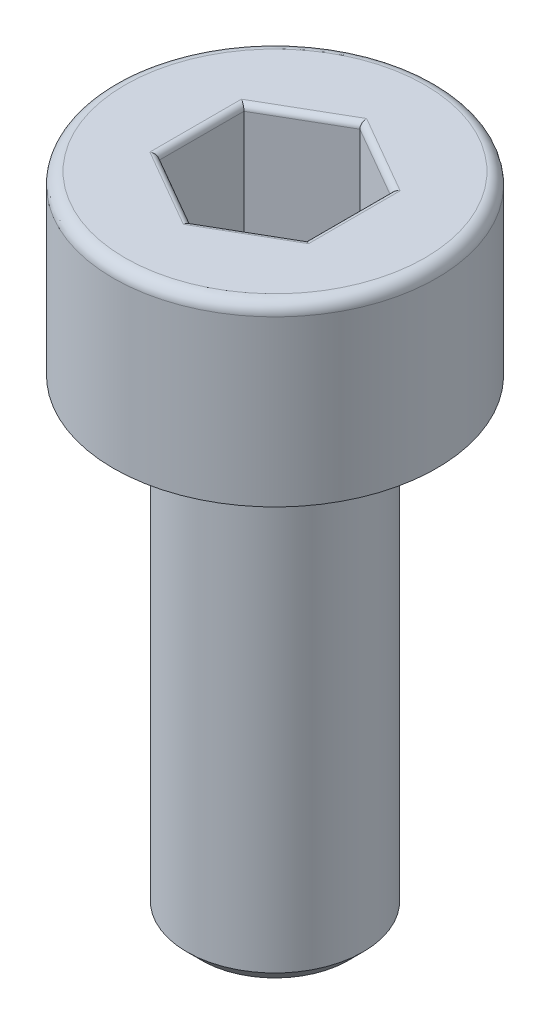
from build123d import *

# Parameters (mm, degrees)
CHAMFER1_SIZE      = 0.25
FILLET1_R          = 0.2
CUT_EXTRUDE1_DEPTH = 2
FILLET2_R          = 0.1


with BuildPart() as part:
    # Sketch1 → Revolve1 (revolve)
    with BuildSketch(Plane.XY):
        Polygon((0, -11), (-1.5, -11), (-1.5, -3), (-2.75, -3), (-2.75, 0), (0, 0), align=None)
    revolve(axis=Axis((0, 0, 0), (0, -1, 0)))

    # Chamfer1
    chamfer1_edges = [part.edges().sort_by_distance(p)[0] for p in [
        (1.5, -3, 0),
        (1.5, -11, 0),
    ]]
    chamfer(chamfer1_edges, length=CHAMFER1_SIZE)

    # Fillet1
    fillet1_edges = [part.edges().sort_by_distance(p)[0] for p in [
        (2.75, 0, 0),
    ]]
    fillet(fillet1_edges, radius=FILLET1_R)

    # Sketch2 → Cut-Extrude1 (cut)
    with BuildSketch(Plane(origin=(0, 0, 0), x_dir=(1, 0, 0), z_dir=(0, 1, 0))):
        Polygon((0, 1.443375673), (-1.25, 0.721687836), (-1.25, -0.721687836), (0, -1.443375673), (1.25, -0.721687836), (1.25, 0.721687836), align=None)
    extrude(amount=-CUT_EXTRUDE1_DEPTH, mode=Mode.SUBTRACT)

    # Fillet2
    fillet2_edges = [part.edges().sort_by_distance(p)[0] for p in [
        (0.625, -2, -1.082531755),
        (1.25, -2, 0),
        (0.625, -2, 1.082531755),
        (-0.625, -2, 1.082531755),
        (-1.25, -2, 0),
        (-0.625, -2, -1.082531755),
        (0.625, 0, -1.082531755),
        (-0.625, 0, -1.082531755),
        (-1.25, 0, 0),
        (-0.625, 0, 1.082531755),
        (0.625, 0, 1.082531755),
        (1.25, 0, 0),
    ]]
    fillet(fillet2_edges, radius=FILLET2_R)


solid = part.part
